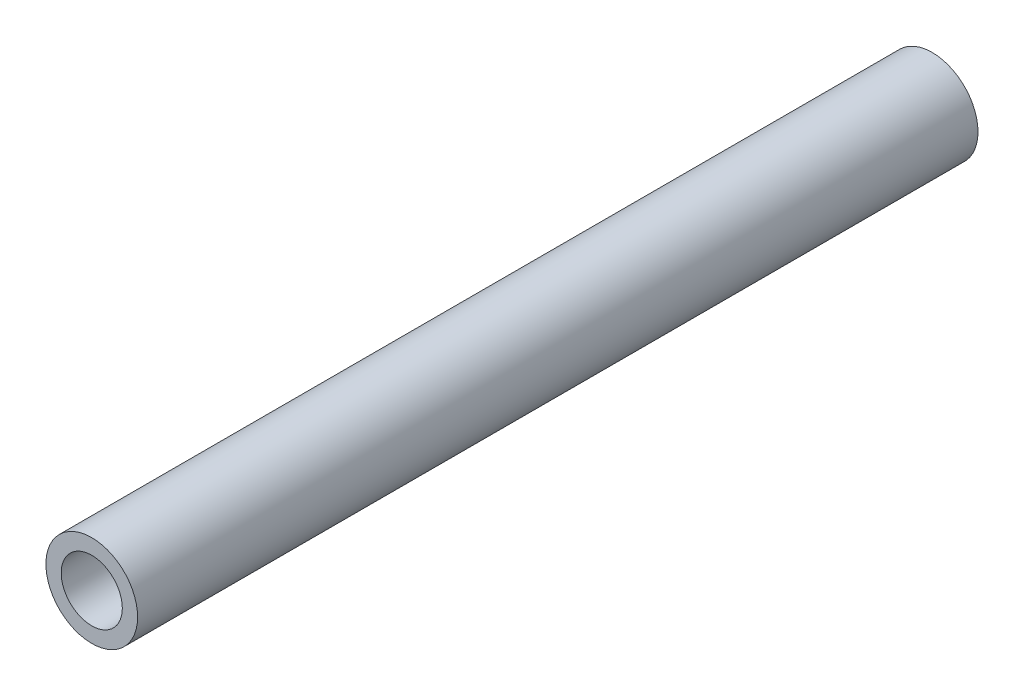
from build123d import *

# Parameters (mm, degrees)
SKETCH_1_R      = 3
SKETCH_1_R_2    = 2
EXTRUDE_1_DEPTH = 27.5


with BuildPart() as part:
    # 草图1 → 凸台-拉伸1 (new body, symmetric)
    with BuildSketch(Plane.XY):
        Circle(SKETCH_1_R)
        Circle(SKETCH_1_R_2, mode=Mode.SUBTRACT)
    extrude(amount=EXTRUDE_1_DEPTH, both=True)


solid = part.part
